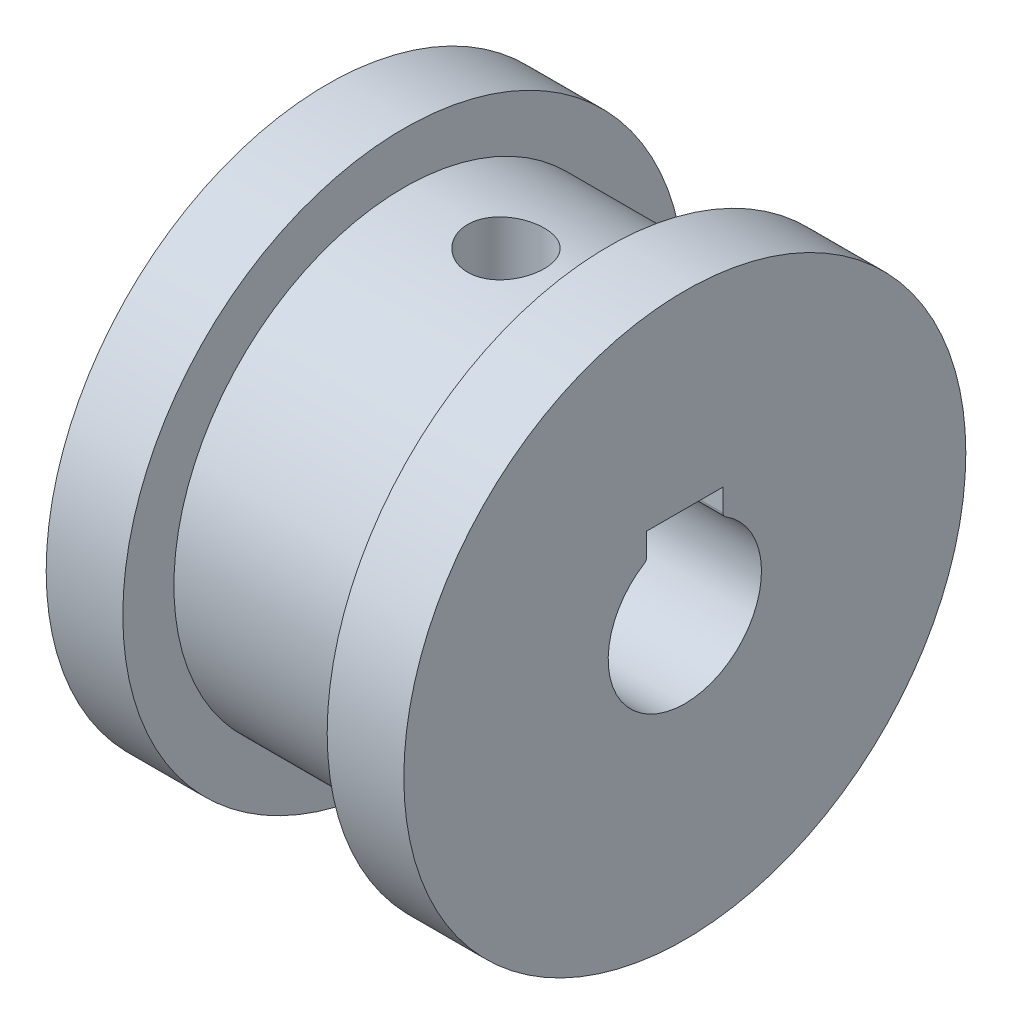
from build123d import *

# Parameters (mm, degrees)
SKETCH1_R               = 9
BOSS_EXTRUDE1_DEPTH     = 8
SKETCH3_R               = 11
BOSS_EXTRUDE2_DEPTH     = 3
SKETCH4_R               = 11
BOSS_EXTRUDE3_DEPTH     = 3
CUT_EXTRUDE2_DEPTH      = 3
CUT_EXTRUDE2_DEPTH_BACK = 11
SKETCH6_R               = 1.5
CUT_EXTRUDE3_DEPTH      = 6


with BuildPart() as part:
    # Sketch1 → Boss-Extrude1 (new body)
    with BuildSketch(Plane(origin=(0, 0, 0), x_dir=(0, 0, -1), z_dir=(1, 0, 0))):
        Circle(SKETCH1_R)
    extrude(amount=BOSS_EXTRUDE1_DEPTH)

    # Sketch3 → Boss-Extrude2 (add)
    with BuildSketch(Plane(origin=(8, 0, 0), x_dir=(0, 0, -1), z_dir=(1, 0, 0))):
        Circle(SKETCH3_R)
    extrude(amount=BOSS_EXTRUDE2_DEPTH)

    # Sketch4 → Boss-Extrude3 (add)
    with BuildSketch(Plane.ZY):
        Circle(SKETCH4_R)
    extrude(amount=BOSS_EXTRUDE3_DEPTH)

    # Sketch2 → Cut-Extrude2 (cut, two sides)
    with BuildSketch(Plane(origin=(8, 0, 0), x_dir=(0, 0, -1), z_dir=(1, 0, 0))) as cut_extrude2_sk:
        with BuildLine():
            Line((-1.5, 3.598076211), (1.5, 3.598076211))
            Line((1.5, 3.598076211), (1.5, 2.711088342))
            ThreePointArc((1.5, 2.711088342), (1.525, 2.614263759), (1.59375, 2.541645321))
            ThreePointArc((1.59375, 2.541645321), (0, -3), (-1.59375, 2.541645321))
            ThreePointArc((-1.59375, 2.541645321), (-1.525, 2.614263759), (-1.5, 2.711088342))
            Line((-1.5, 2.711088342), (-1.5, 3.598076211))
        make_face()
    extrude(amount=CUT_EXTRUDE2_DEPTH, mode=Mode.SUBTRACT)
    extrude(cut_extrude2_sk.sketch, amount=-CUT_EXTRUDE2_DEPTH_BACK, mode=Mode.SUBTRACT)

    # Sketch6 → Cut-Extrude3 (cut)
    with BuildSketch(Plane.XZ.offset(-3.598076211)):
        with Locations((4, 0)):
            Circle(SKETCH6_R)
    extrude(amount=-CUT_EXTRUDE3_DEPTH, mode=Mode.SUBTRACT)


solid = part.part
